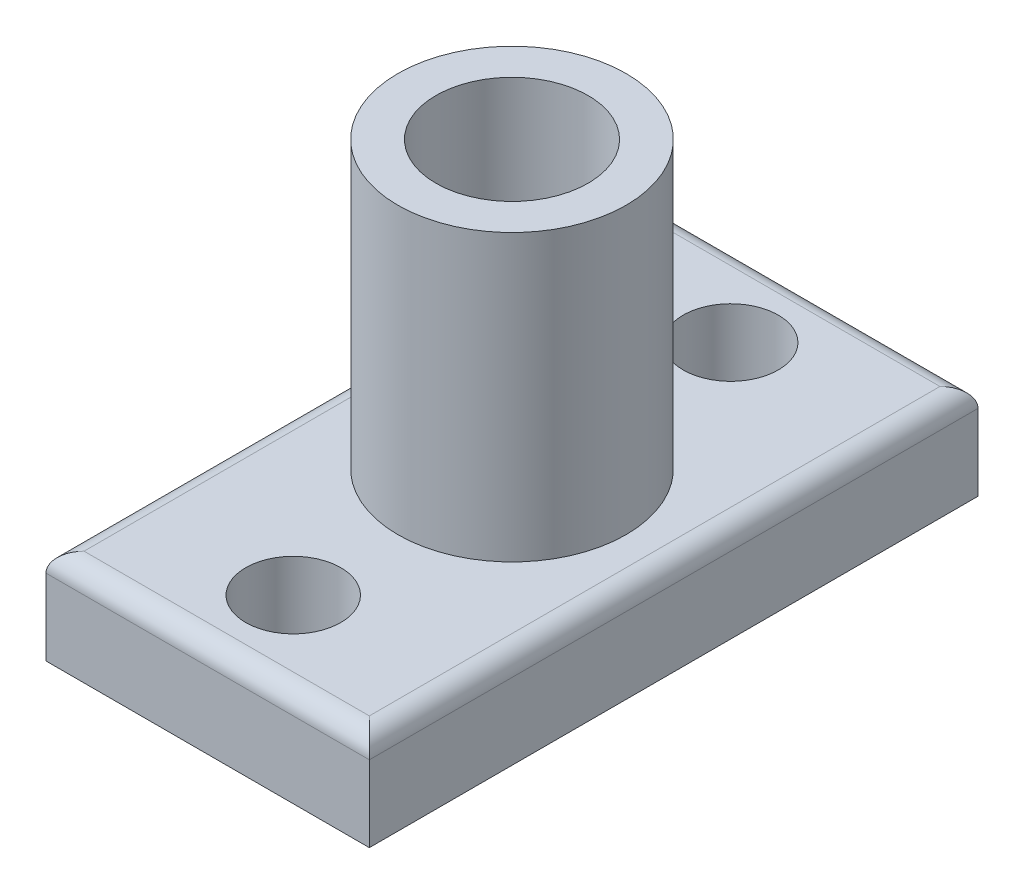
from build123d import *

# Parameters (mm, degrees)
SKETCH1_W           = 17
SKETCH1_H           = 32
SKETCH1_R           = 2.5
BOSS_EXTRUDE1_DEPTH = 5
SKETCH2_R           = 6
SKETCH2_R_2         = 4
BOSS_EXTRUDE2_DEPTH = 15
FILLET1_R           = 1


with BuildPart() as part:
    # Sketch1 → Boss-Extrude1 (new body)
    with BuildSketch(Plane(origin=(0, 0, 0), x_dir=(1, 0, 0), z_dir=(0, 1, 0))):
        Rectangle(SKETCH1_W, SKETCH1_H)
        with Locations((0, 11.5)):
            Circle(SKETCH1_R, mode=Mode.SUBTRACT)
        with Locations((0, -11.5)):
            Circle(SKETCH1_R, mode=Mode.SUBTRACT)
    extrude(amount=BOSS_EXTRUDE1_DEPTH)

    # Sketch2 → Boss-Extrude2 (add)
    with BuildSketch(Plane(origin=(0, 5, 0), x_dir=(1, 0, 0), z_dir=(0, 1, 0))):
        Circle(SKETCH2_R)
        Circle(SKETCH2_R_2, mode=Mode.SUBTRACT)
    extrude(amount=BOSS_EXTRUDE2_DEPTH)

    # Fillet1
    fillet1_edges = [part.edges().sort_by_distance(p)[0] for p in [
        (-8.5, 5, 0),
        (0, 5, 16),
        (8.5, 5, 0),
        (0, 5, -16),
    ]]
    fillet(fillet1_edges, radius=FILLET1_R)


solid = part.part
